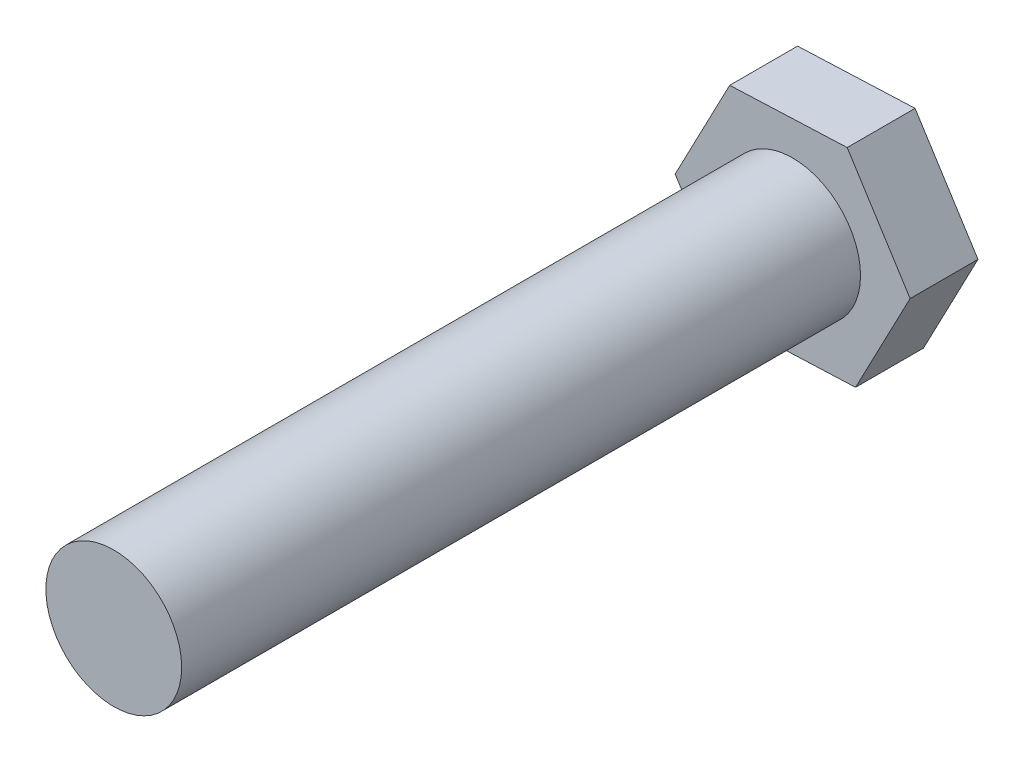
from build123d import *

# Parameters (mm, degrees)
BOSS_EXTRUDE1_DEPTH = 2
SKETCH2_R           = 2
BOSS_EXTRUDE2_DEPTH = 20


with BuildPart() as part:
    # Sketch1 → Boss-Extrude1 (new body)
    with BuildSketch(Plane.XY):
        Polygon((1.853941848, -2.926243261), (3.461171926, 0.142439107), (1.607230078, 3.068682368), (-1.853941848, 2.926243261), (-3.461171926, -0.142439107), (-1.607230078, -3.068682368), align=None)
    extrude(amount=BOSS_EXTRUDE1_DEPTH)

    # Sketch2 → Boss-Extrude2 (add)
    with BuildSketch(Plane.XY.offset(2)):
        Circle(SKETCH2_R)
    extrude(amount=BOSS_EXTRUDE2_DEPTH)


solid = part.part
